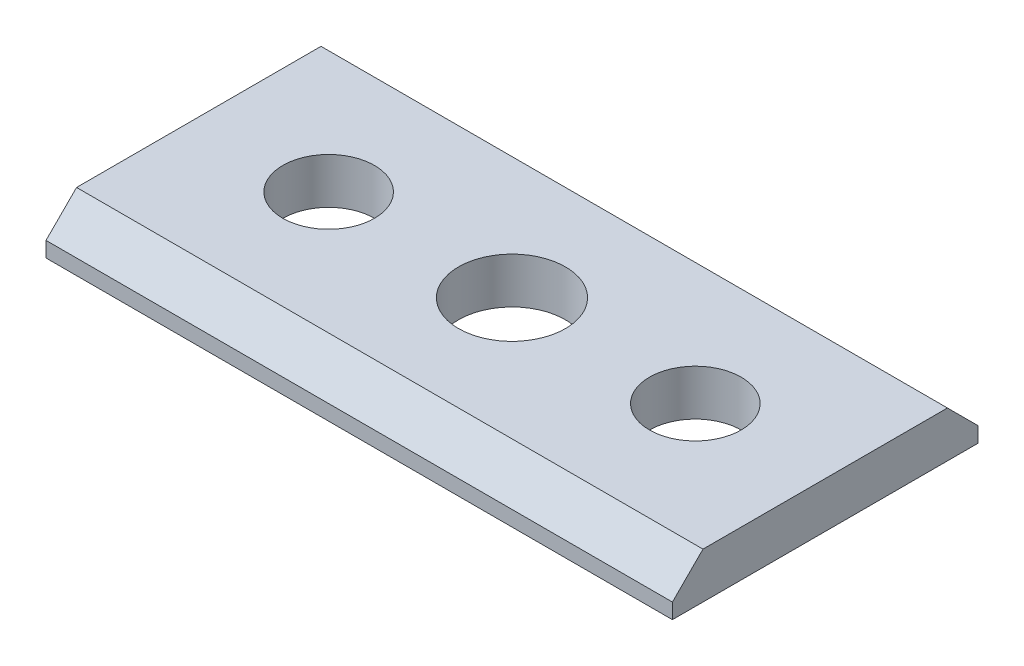
from build123d import *

# Parameters (mm, degrees)
SKETCH1_W           = 41
SKETCH1_H           = 20
BOSS_EXTRUDE1_DEPTH = 3
SKETCH7_R           = 3
SKETCH7_R_2         = 3.5
HOLES_DEPTH         = 4
CHAMFER1_SIZE       = 2


with BuildPart() as part:
    # Sketch1 → Boss-Extrude1 (new body)
    with BuildSketch(Plane(origin=(0, 0, 0), x_dir=(1, 0, 0), z_dir=(0, 1, 0))):
        with Locations((20.5, 10)):
            Rectangle(SKETCH1_W, SKETCH1_H)
    extrude(amount=-BOSS_EXTRUDE1_DEPTH)

    # Sketch7 → holes (cut, through all)
    with BuildSketch(Plane(origin=(0, 0, 0), x_dir=(1, 0, 0), z_dir=(0, 1, 0))):
        with Locations((8.5, 10)):
            Circle(SKETCH7_R)
        with Locations((32.5, 10)):
            Circle(SKETCH7_R)
        with Locations((20.5, 10)):
            Circle(SKETCH7_R_2)
    extrude(amount=-HOLES_DEPTH, mode=Mode.SUBTRACT)

    # Chamfer1
    chamfer1_edges = [part.edges().sort_by_distance(p)[0] for p in [
        (20.5, 0, 0),
        (20.5, 0, -20),
    ]]
    chamfer(chamfer1_edges, length=CHAMFER1_SIZE)


solid = part.part
